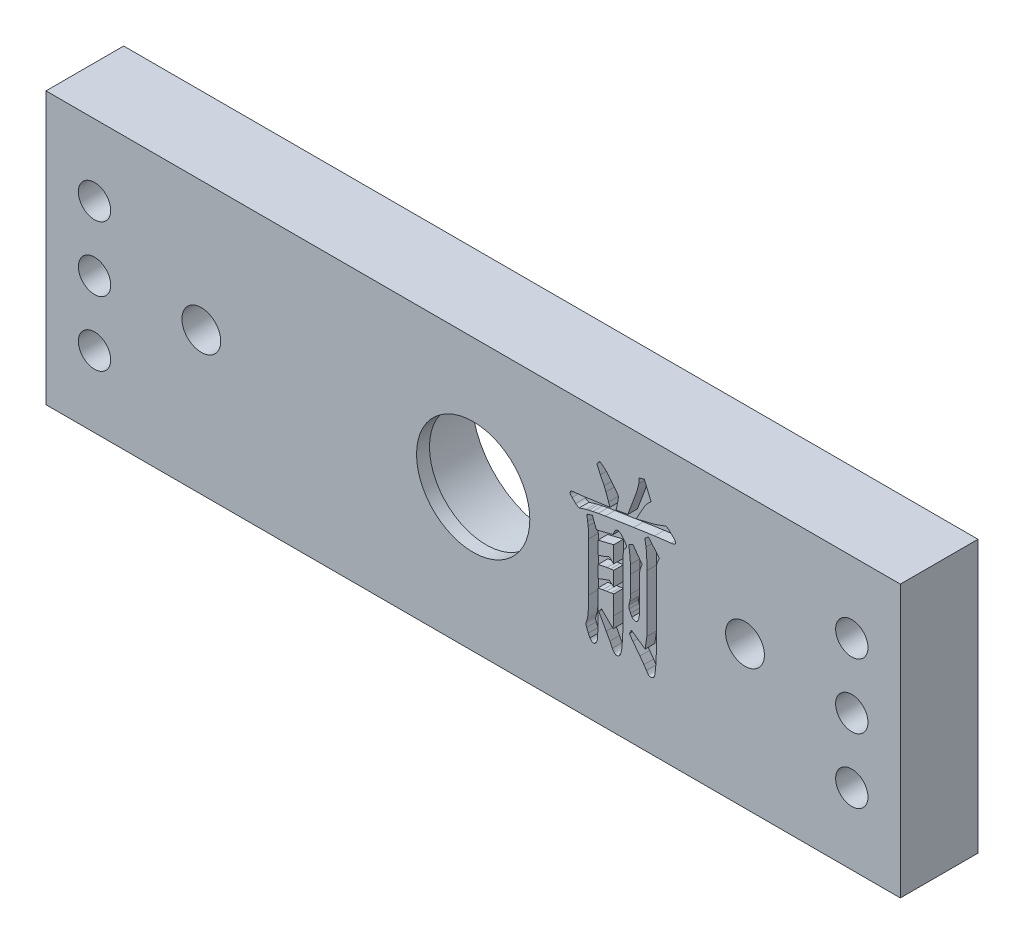
from build123d import *

# Parameters (mm, degrees)
SKETCH_1_W          = 132
SKETCH_1_H          = 42
EXTRUDE_1_DEPTH     = 12
SKETCH_2_R          = 12.25
CUT_EXTRUDE_1_DEPTH = 10
SKETCH_3_R          = 4.1
CUT_EXTRUDE_2_DEPTH = 4
SKETCH_4_R          = 8.75
CUT_EXTRUDE_3_DEPTH = 6
SKETCH_5_R          = 3
CUT_EXTRUDE_4_DEPTH = 8
CUT_EXTRUDE_6_DEPTH = 1.5
SKETCH_7_R          = 2.5
CUT_EXTRUDE_7_DEPTH = 12


with BuildPart() as part:
    # 草图1 → 凸台-拉伸1 (new body)
    with BuildSketch(Plane.XY):
        with Locations((0, -1)):
            Rectangle(SKETCH_1_W, SKETCH_1_H)
    extrude(amount=EXTRUDE_1_DEPTH)

    # 草图2 → 切除-拉伸1 (cut)
    with BuildSketch(Plane(origin=(0, 0, 0), x_dir=(-1, 0, 0), z_dir=(0, 0, -1))):
        Circle(SKETCH_2_R)
    extrude(amount=-CUT_EXTRUDE_1_DEPTH, mode=Mode.SUBTRACT)

    # 草图3 → 切除-拉伸2 (cut)
    with BuildSketch(Plane(origin=(0, 0, 0), x_dir=(-1, 0, 0), z_dir=(0, 0, -1))):
        with Locations((-42, 0)):
            Circle(SKETCH_3_R)
        with Locations((42, 0)):
            Circle(SKETCH_3_R)
    extrude(amount=-CUT_EXTRUDE_2_DEPTH, mode=Mode.SUBTRACT)

    # 草图4 → 切除-拉伸3 (cut)
    with BuildSketch(Plane(origin=(0, 0, 10), x_dir=(-1, 0, 0), z_dir=(0, 0, -1))):
        Circle(SKETCH_4_R)
    extrude(amount=-CUT_EXTRUDE_3_DEPTH, mode=Mode.SUBTRACT)

    # 草图5 → 切除-拉伸4 (cut)
    with BuildSketch(Plane(origin=(0, 0, 4), x_dir=(-1, 0, 0), z_dir=(0, 0, -1))):
        with Locations((-42, 0)):
            Circle(SKETCH_5_R)
        with Locations((42, 0)):
            Circle(SKETCH_5_R)
    extrude(amount=-CUT_EXTRUDE_4_DEPTH, mode=Mode.SUBTRACT)

    # 草图6 → 切除-拉伸6 (cut)
    with BuildSketch(Plane.XY.offset(12)):
        with BuildLine():
            Line((25.191758998, 8.327165962), (27.114632327, 8.792123038))
            Line((27.114632327, 8.792123038), (27.697798828, 8.918213092))
            Line((27.697798828, 8.918213092), (28.284905644, 9.095527231))
            Line((28.284905644, 9.095527231), (28.899594659, 9.328005769))
            Line((28.899594659, 9.328005769), (29.147834453, 9.426513624))
            Line((29.147834453, 9.426513624), (29.817687867, 9.658992161))
            Line((29.817687867, 9.658992161), (30.298406199, 9.328005769))
            Line((30.298406199, 9.328005769), (30.830348616, 8.827585866))
            add(Edge.make_bspline(
                [(30.830348616, 8.827585866), (30.974392324, 8.694498254), (31.139102534, 8.498950147), (31.284197907, 8.230119608), (31.286061157, 8.072378676), (31.198510591, 7.952136811), (30.969317793, 7.822598813), (30.747528982, 7.799916096), (30.58998945, 7.77158166)],
                knots=[0, 0, 0, 0, 0.347386009, 0.457637151, 0.537409731, 0.613512621, 0.710464893, 1, 1, 1, 1], degree=3))
            Line((30.58998945, 7.77158166), (28.020904592, 7.460296839))
            Line((28.020904592, 7.460296839), (24.809548521, 6.987459135))
            Line((24.809548521, 6.987459135), (20.400336934, 6.309725093))
            Line((20.400336934, 6.309725093), (19.320690843, 6.12847064))
            Line((19.320690843, 6.12847064), (18.469582976, 5.947216187))
            Line((18.469582976, 5.947216187), (17.870655218, 5.817185818))
            Line((17.870655218, 5.817185818), (17.492385055, 5.73443922))
            Line((17.492385055, 5.73443922), (16.400918023, 5.403452827))
            add(Edge.make_bspline(
                [(16.400918023, 5.403452827), (16.072768679, 5.475519222), (15.841393406, 5.722618277)],
                knots=[0, 0, 0, 1, 1, 1], degree=2))
            Line((15.841393406, 5.722618277), (15.297630047, 6.242739752))
            add(Edge.make_bspline(
                [(15.297630047, 6.242739752), (15.213988759, 6.321306927), (15.099784073, 6.426220558), (15.004973033, 6.582662061), (14.956034093, 6.779294005), (15.065682257, 6.938782403), (15.100614337, 7.054444476)],
                knots=[0, 0, 0, 0, 0.367731092, 0.487674472, 0.578038932, 1, 1, 1, 1], degree=3))
            Line((15.100614337, 7.054444476), (17.129876149, 7.279042386))
            Line((17.129876149, 7.279042386), (20.967742178, 7.826746059))
            Line((20.967742178, 7.826746059), (21.133550529, 7.843326893))
            add(Edge.make_bspline(
                [(21.133550529, 7.843326893), (21.131328625, 7.848770326), (21.12929506, 7.854328259)],
                knots=[0.992818923, 0.992818923, 0.992818923, 1, 1, 1], degree=2))
            Line((21.12929506, 7.854328259), (20.920458408, 8.461136645))
            Line((20.920458408, 8.461136645), (20.502785103, 9.599887448))
            Line((20.502785103, 9.599887448), (20.226963109, 10.285502119))
            Line((20.226963109, 10.285502119), (19.65561755, 11.45971575))
            Line((19.65561755, 11.45971575), (19.107913877, 12.685153465))
            Line((19.107913877, 12.685153465), (19.584691895, 13.209215254))
            Line((19.584691895, 13.209215254), (20.44368039, 12.519660269))
            Line((20.44368039, 12.519660269), (20.944100293, 11.940434082))
            Line((20.944100293, 11.940434082), (21.416937997, 11.365148209))
            Line((21.416937997, 11.365148209), (22.000104498, 10.655891653))
            add(Edge.make_bspline(
                [(22.000104498, 10.655891653), (22.110177597, 10.508306337), (22.256510949, 10.312242366), (22.395499382, 10.063105084), (22.471673816, 9.797667481), (22.391071516, 9.576952393), (22.386255289, 9.410752367)],
                knots=[0, 0, 0, 0, 0.402738177, 0.535125963, 0.621582834, 1, 1, 1, 1], degree=3))
            Line((22.386255289, 9.410752367), (22.173478323, 8.36262879))
            add(Edge.make_bspline(
                [(22.173478323, 8.36262879), (22.149097512, 8.226139771), (22.113434597, 8.090684095), (22.054291009, 7.965568561)],
                knots=[0, 0, 0, 0, 0.260339199, 0.260339199, 0.260339199, 0.260339199], degree=3))
            Line((22.054291009, 7.965568561), (22.350792462, 8.011940827))
            Line((22.350792462, 8.011940827), (23.875694056, 8.248359678))
            add(Edge.make_bspline(
                [(23.875694056, 8.248359678), (24.003524188, 8.58988521), (24.200647973, 9.076243154), (24.431679742, 9.705000245), (24.593465388, 10.107768552), (24.724490065, 10.474190647), (24.848385306, 10.79434655), (24.950674681, 11.075981958), (25.062157101, 11.386002356), (25.184280795, 11.721789101), (25.301554972, 12.083415972), (25.395390137, 12.395415351), (25.45599562, 12.659857653), (25.503565146, 12.872857365), (25.542585688, 13.056120101), (25.56987741, 13.167563547), (25.585790418, 13.22497651)],
                knots=[0, 0, 0, 0, 0.207633328, 0.298753252, 0.381388111, 0.454739912, 0.520300853, 0.576847563, 0.6253436, 0.707897199, 0.780266428, 0.841800773, 0.89331668, 0.934686531, 0.966079053, 1, 1, 1, 1], degree=3))
            Line((25.585790418, 13.22497651), (25.644895131, 14.024860293))
            Line((25.644895131, 14.024860293), (26.440838599, 14.253398516))
            Line((26.440838599, 14.253398516), (27.488962176, 11.751299))
            add(Edge.make_bspline(
                [(27.488962176, 11.751299), (27.316634448, 11.60393258), (27.07820583, 11.389971562), (26.806382933, 11.098446066), (26.669373385, 10.927265099), (26.563035487, 10.765215211), (26.455570939, 10.58898711), (26.320342644, 10.353601444), (26.148933384, 10.062591805), (25.953451454, 9.71026665), (25.62701749, 9.127639525), (25.371965579, 8.658714537), (25.191758998, 8.327165962)],
                knots=[0, 0, 0, 0, 0.163792496, 0.230901787, 0.287626284, 0.3218181, 0.37077333, 0.436645072, 0.517807364, 0.614614013, 0.727538624, 1, 1, 1, 1], degree=3))
        make_face()
        with BuildLine():
            Line((19.040928535, 3.787924006), (21.606073078, 4.430195221))
            Line((21.606073078, 4.430195221), (21.866133815, 5.037003607))
            add(Edge.make_bspline(
                [(21.866133815, 5.037003607), (21.931571672, 5.160255421), (22.06666113, 5.313893604), (22.311011557, 5.377344607), (22.585302853, 5.309424165), (22.772144506, 5.172906983), (22.910317078, 5.072466435)],
                knots=[0, 0, 0, 0, 0.341138446, 0.451230624, 0.589089278, 1, 1, 1, 1], degree=3))
            Line((22.910317078, 5.072466435), (23.418617609, 4.438075849))
            add(Edge.make_bspline(
                [(23.418617609, 4.438075849), (23.491135168, 4.328393102), (23.591004327, 4.186636674), (23.674821198, 4.004500239), (23.698299526, 3.867048046), (23.65715392, 3.772799383), (23.63533489, 3.709117722)],
                knots=[0, 0, 0, 0, 0.489758252, 0.643142666, 0.741980853, 1, 1, 1, 1], degree=3))
            Line((23.63533489, 3.709117722), (23.225542213, 3.185055934))
            add(Edge.make_bspline(
                [(23.225542213, 3.185055934), (23.203472038, 3.105376946), (23.186372352, 2.990523099), (23.181914109, 2.827810155), (23.174099116, 2.608535574), (23.181214579, 2.421905268), (23.178258443, 2.282723983)],
                knots=[0, 0, 0, 0, 0.273514135, 0.382334398, 0.538970761, 1, 1, 1, 1], degree=3))
            Line((23.178258443, 2.282723983), (23.178258443, -5.917069863))
            add(Edge.make_bspline(
                [(23.178258443, -5.917069863), (23.180464517, -6.039256341), (23.174288114, -6.237541099), (23.170933512, -6.523918686), (23.162732466, -6.785311636), (23.149862888, -7.078116612), (23.138086473, -7.402542011), (23.127537993, -7.758577095), (23.106112982, -8.255051707), (23.080811137, -8.841213186), (23.038391847, -9.466674595), (22.989953908, -9.973035386), (22.930832317, -10.368810276), (22.866114178, -10.675052361), (22.800842675, -10.914511511), (22.730238913, -11.098458531), (22.620347522, -11.267764571), (22.426703148, -11.39711658), (22.201250372, -11.473481253), (21.985950282, -11.437904866), (21.729331617, -11.241460133), (21.60533602, -11.003611118), (21.507565223, -10.834581983)],
                knots=[0, 0, 0, 0, 0.053419296, 0.086735995, 0.125233949, 0.167770057, 0.214897485, 0.267190863, 0.323523097, 0.432196453, 0.523734868, 0.597628633, 0.654569503, 0.698614342, 0.734431276, 0.763015897, 0.784521094, 0.821511476, 0.862615962, 0.885373184, 0.913888481, 1, 1, 1, 1], degree=3))
            Line((21.507565223, -10.834581983), (21.117474118, -10.054399771))
            Line((21.117474118, -10.054399771), (20.546128559, -9.018097137))
            Line((20.546128559, -9.018097137), (19.395556813, -6.937611241))
            Line((19.395556813, -6.937611241), (19.828991375, -6.393847881))
            Line((19.828991375, -6.393847881), (21.621834335, -8.159108642))
            Line((21.621834335, -8.159108642), (21.72034219, -6.358385054))
            Line((21.72034219, -6.358385054), (21.72034219, -3.452512569))
            add(Edge.make_bspline(
                [(21.72034219, -3.452512569), (21.584513636, -3.488472035), (21.445424396, -3.511821942), (21.306609199, -3.533179774)],
                knots=[0.741321326, 0.741321326, 0.741321326, 0.741321326, 1, 1, 1, 1], degree=3))
            Line((21.306609199, -3.533179774), (20.6131139, -3.635627943))
            Line((20.6131139, -3.635627943), (20.02206677, -3.742016426))
            Line((20.02206677, -3.742016426), (19.28916833, -3.872046795))
            Line((19.28916833, -3.872046795), (19.285228015, -8.139407071))
            Line((19.285228015, -8.139407071), (19.257645816, -9.660368352))
            Line((19.257645816, -9.660368352), (19.202481417, -10.680909729))
            add(Edge.make_bspline(
                [(19.202481417, -10.680909729), (19.188618314, -10.845174202), (19.15376078, -11.095915287), (18.975986069, -11.363009069), (18.822599248, -11.51679997), (18.629865562, -11.611999679), (18.301902729, -11.552638301), (18.141762106, -11.325580576), (18.032208101, -11.18921026)],
                knots=[0, 0, 0, 0, 0.265053304, 0.383705508, 0.501207406, 0.607272201, 0.707999035, 1, 1, 1, 1], degree=3))
            Line((18.032208101, -11.18921026), (17.791848934, -10.680909729))
            Line((17.791848934, -10.680909729), (17.535728512, -10.014996629))
            add(Edge.make_bspline(
                [(17.535728512, -10.014996629), (17.477301436, -9.885056743), (17.396047164, -9.692290474), (17.448815149, -9.453284009), (17.487035225, -9.292579646), (17.551106489, -9.08231968), (17.629948214, -8.871413012), (17.684470032, -8.644036758), (17.72162692, -8.401579775), (17.757263132, -8.092817725), (17.782935577, -7.718088693), (17.801299627, -7.276590531), (17.824927681, -6.556923712), (17.823998956, -5.982708956), (17.827311762, -5.578202842)],
                knots=[0, 0, 0, 0, 0.100292511, 0.12521781, 0.162200464, 0.210716058, 0.271682213, 0.312278001, 0.366447477, 0.435254483, 0.51960521, 0.616976125, 0.730076622, 1, 1, 1, 1], degree=3))
            Line((17.827311762, -5.578202842), (17.827311762, 1.967498847))
            add(Edge.make_bspline(
                [(17.827311762, 1.967498847), (17.824489372, 2.289280856), (17.824199366, 2.8519616), (17.797425725, 3.414104238), (17.776087678, 3.653953324)],
                knots=[0, 0, 0, 0, 0.572057131, 1, 1, 1, 1], degree=3))
            Line((17.776087678, 3.653953324), (17.673639508, 4.248940767))
            Line((17.673639508, 4.248940767), (17.567251025, 5.147332405))
            Line((17.567251025, 5.147332405), (18.410478264, 5.431035027))
            Line((18.410478264, 5.431035027), (19.040928535, 3.787924006))
        make_face()
        with BuildLine():
            Line((21.72034219, 3.125951221), (19.28916833, 2.538844405))
            Line((19.28916833, 2.538844405), (19.28916833, 0.521403536))
            add(Edge.make_bspline(
                [(19.28916833, 0.521403536), (19.606724225, 0.616982671), (20.193855483, 0.795827986), (20.752853578, 1.049096173), (21.003205006, 1.175495693)],
                knots=[0, 0, 0, 0, 0.541942068, 1, 1, 1, 1], degree=3))
            Line((21.003205006, 1.175495693), (21.72034219, 0.562669372))
            Line((21.72034219, 0.562669372), (21.72034219, 3.125951221))
        make_face(mode=Mode.SUBTRACT)
        with BuildLine():
            Line((21.212041658, -0.373047787), (20.684039556, -0.436092814))
            Line((20.684039556, -0.436092814), (19.28916833, -0.731616379))
            Line((19.28916833, -0.731616379), (19.28916833, -2.611146251))
            add(Edge.make_bspline(
                [(19.28916833, -2.611146251), (19.552316809, -2.516541816), (20.139800205, -2.303014882), (20.723588438, -2.079574595), (21.046548462, -1.957054094)],
                knots=[0, 0, 0, 0, 0.447377695, 1, 1, 1, 1], degree=3))
            Line((21.046548462, -1.957054094), (21.72034219, -2.53912721))
            Line((21.72034219, -2.53912721), (21.72034219, -0.293246252))
            add(Edge.make_bspline(
                [(21.72034219, -0.293246252), (21.552983365, -0.331244596), (21.382490468, -0.356152803), (21.212041658, -0.373047787)],
                knots=[0.675613167, 0.675613167, 0.675613167, 0.675613167, 1, 1, 1, 1], degree=3))
        make_face(mode=Mode.SUBTRACT)
        with BuildLine():
            Line((24.041187252, 4.319866423), (24.703160038, 4.623270616))
            Line((24.703160038, 4.623270616), (26.129553777, 2.641292575))
            add(Edge.make_bspline(
                [(26.129553777, 2.641292575), (25.989284888, 2.428695326), (25.77436412, 1.938127979), (25.713312531, 1.406612821), (25.711880472, 1.132152237)],
                knots=[0, 0, 0, 0, 0.480508613, 1, 1, 1, 1], degree=3))
            Line((25.711880472, 1.132152237), (25.711880472, -3.643508571))
            add(Edge.make_bspline(
                [(25.711880472, -3.643508571), (25.714904868, -3.956757563), (25.690266067, -4.394983465), (25.56854522, -4.918908576), (25.469202179, -5.168353495), (25.363413593, -5.31792916), (25.277420792, -5.395692113), (25.176038336, -5.439848456), (25.064256851, -5.439646759), (24.943531536, -5.415052229), (24.752358334, -5.332033313), (24.624655437, -5.220839483), (24.533726527, -5.144768281)],
                knots=[0, 0, 0, 0, 0.351022666, 0.487127426, 0.600936387, 0.648242563, 0.690945408, 0.729139994, 0.768830798, 0.813774246, 0.866434145, 1, 1, 1, 1], degree=3))
            Line((24.533726527, -5.144768281), (24.324889875, -4.750736861))
            Line((24.324889875, -4.750736861), (24.108172594, -4.270018529))
            add(Edge.make_bspline(
                [(24.108172594, -4.270018529), (24.024247918, -4.032220753), (24.045127567, -3.781419568)],
                knots=[0, 0, 0, 1, 1, 1], degree=2))
            Line((24.045127567, -3.781419568), (24.183038564, -3.277059351))
            add(Edge.make_bspline(
                [(24.183038564, -3.277059351), (24.234642484, -3.136011268), (24.291490075, -2.763066979), (24.334431828, -2.389641394), (24.328830189, -2.161950433)],
                knots=[0, 0, 0, 0, 0.397178449, 1, 1, 1, 1], degree=3))
            Line((24.328830189, -2.161950433), (24.30124799, 0.474119766))
            Line((24.30124799, 0.474119766), (24.30124799, 1.798065336))
            add(Edge.make_bspline(
                [(24.30124799, 1.798065336), (24.283405884, 2.060676161), (24.266108324, 2.414585313), (24.223758797, 2.893724136), (24.164391874, 3.47294232), (24.089532809, 3.958716461), (24.041187252, 4.319866423)],
                knots=[0, 0, 0, 0, 0.311368188, 0.418968206, 0.568916741, 1, 1, 1, 1], degree=3))
        make_face()
        with BuildLine():
            Line((24.462800872, -6.941551555), (26.570868968, -8.415229065))
            Line((26.570868968, -8.415229065), (26.834870019, -6.594803905))
            Line((26.834870019, -6.594803905), (26.834870019, 2.227559584))
            add(Edge.make_bspline(
                [(26.834870019, 2.227559584), (26.825166819, 2.671360668), (26.840492962, 3.277298464), (26.812785299, 4.003392001), (26.798320793, 4.381811473), (26.778457866, 4.680087518), (26.748078674, 4.982278722), (26.725037902, 5.188624665), (26.70483965, 5.312825601)],
                knots=[0, 0, 0, 0, 0.430919252, 0.587813193, 0.705213562, 0.798498326, 0.877910557, 1, 1, 1, 1], degree=3))
            Line((26.70483965, 5.312825601), (26.523585197, 6.384591063))
            Line((26.523585197, 6.384591063), (27.083109813, 6.865309395))
            Line((27.083109813, 6.865309395), (28.765623976, 4.843928211))
            add(Edge.make_bspline(
                [(28.765623976, 4.843928211), (28.665330479, 4.626717443), (28.515903082, 4.330434565), (28.395146067, 3.950606625), (28.336423116, 3.726236635), (28.323008224, 3.485804722), (28.295629121, 3.038676353), (28.301951756, 2.661986229), (28.296726586, 2.385172152)],
                knots=[0, 0, 0, 0, 0.283363995, 0.389307166, 0.470566222, 0.556220788, 0.672708106, 1, 1, 1, 1], degree=3))
            Line((28.296726586, 2.385172152), (28.296726586, -8.186690841))
            add(Edge.make_bspline(
                [(28.296726586, -8.186690841), (28.298685239, -8.487870992), (28.268771334, -9.054161484), (28.232761267, -9.619950265), (28.210039674, -9.884966261)],
                knots=[0, 0, 0, 0, 0.53090527, 1, 1, 1, 1], degree=3))
            Line((28.210039674, -9.884966261), (28.13123339, -10.669088786))
            add(Edge.make_bspline(
                [(28.13123339, -10.669088786), (28.09764254, -10.914313148), (28.067642249, -11.245259407), (27.867313059, -11.597996588), (27.681849506, -11.695325773), (27.515891024, -11.713432147), (27.374660994, -11.722693973), (27.262608333, -11.720860282), (27.163999979, -11.703712414), (27.080552703, -11.632353775), (26.933266189, -11.464251746), (26.847809711, -11.285879835), (26.767884677, -11.165568375)],
                knots=[0, 0, 0, 0, 0.315763983, 0.418272319, 0.498355371, 0.571214956, 0.629844232, 0.678372483, 0.714474507, 0.753944421, 0.814359291, 1, 1, 1, 1], degree=3))
            Line((26.767884677, -11.165568375), (26.377793572, -10.57846156))
            Line((26.377793572, -10.57846156), (25.770985185, -9.723413379))
            Line((25.770985185, -9.723413379), (24.691339095, -8.340363095))
            Line((24.691339095, -8.340363095), (24.147575736, -7.540479313))
            Line((24.147575736, -7.540479313), (24.462800872, -6.941551555))
        make_face()
    extrude(amount=-CUT_EXTRUDE_6_DEPTH, mode=Mode.SUBTRACT)

    # 草图7 → 切除-拉伸7 (cut)
    with BuildSketch(Plane(origin=(0, 0, 0), x_dir=(-1, 0, 0), z_dir=(0, 0, -1))):
        with Locations((58.5, 9)):
            Circle(SKETCH_7_R)
        with Locations((58.5, -1)):
            Circle(SKETCH_7_R)
        with Locations((58.5, -11)):
            Circle(SKETCH_7_R)
        with Locations((-58.5, -11)):
            Circle(SKETCH_7_R)
        with Locations((-58.5, -1)):
            Circle(SKETCH_7_R)
        with Locations((-58.5, 9)):
            Circle(SKETCH_7_R)
    extrude(amount=-CUT_EXTRUDE_7_DEPTH, mode=Mode.SUBTRACT)


solid = part.part
